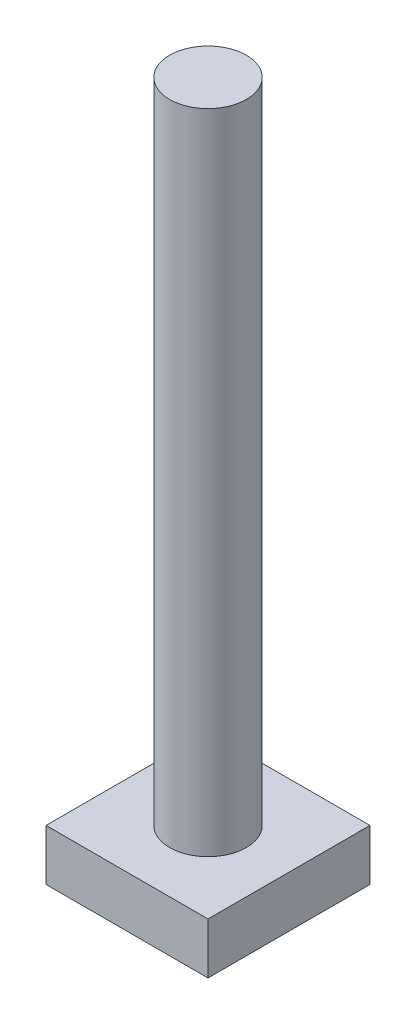
from build123d import *

# Parameters (mm, degrees)
SKETCH1_W           = 19
SKETCH1_H           = 19
BOSS_EXTRUDE1_DEPTH = 6
SKETCH2_R           = 4.5
BOSS_EXTRUDE2_DEPTH = 76


with BuildPart() as part:
    # Sketch1 → Boss-Extrude1 (new body)
    with BuildSketch(Plane(origin=(0, 0, 0), x_dir=(1, 0, 0), z_dir=(0, 1, 0))):
        Rectangle(SKETCH1_W, SKETCH1_H)
    extrude(amount=BOSS_EXTRUDE1_DEPTH)

    # Sketch2 → Boss-Extrude2 (add)
    with BuildSketch(Plane(origin=(0, 6, 0), x_dir=(1, 0, 0), z_dir=(0, 1, 0))):
        with Locations(Location((0, 0, 0), (0, 0, 270))):  # turned: the seam where the file's is
            Circle(SKETCH2_R)
    extrude(amount=BOSS_EXTRUDE2_DEPTH)


solid = part.part
